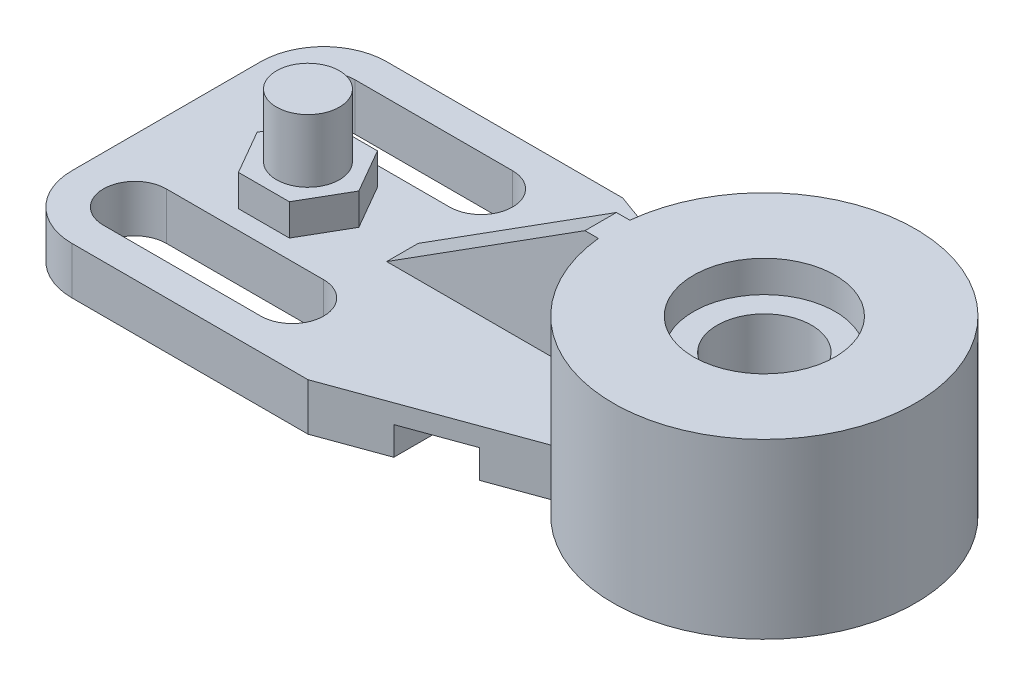
from build123d import *

# Parameters (mm, degrees)
BOSS_EXTRUDE1_DEPTH = 31.75
FILLET1_R           = 12.7
CUT_EXTRUDE1_DEPTH  = 63.5
SKETCH5_R           = 30.48
BOSS_EXTRUDE2_DEPTH = 34.925
SKETCH6_R           = 9.525
CUT_EXTRUDE2_DEPTH  = 35.925
SKETCH7_R           = 14.2875
CUT_EXTRUDE3_DEPTH  = 6.35
CUT_EXTRUDE4_DEPTH  = 10.525
BOSS_EXTRUDE6_DEPTH = 3.175
BOSS_EXTRUDE7_DEPTH = 6.35
SKETCH11_R          = 6.35
BOSS_EXTRUDE8_DEPTH = 12.7


with BuildPart() as part:
    # Sketch2 → Boss-Extrude1 (new body, symmetric)
    with BuildSketch(Plane.XY):
        Polygon((0, 0), (0, 9.525), (-120.65, 9.525), (-120.65, 0), (-47.625, 0), (-47.625, 5.715), (-34.925, 5.715), (-34.925, 0), align=None)
    extrude(amount=BOSS_EXTRUDE1_DEPTH, both=True)

    # Fillet1
    fillet1_edges = [part.edges().sort_by_distance(p)[0] for p in [
        (-120.65, 4.7625, -31.75),
        (-120.65, 4.7625, 31.75),
    ]]
    fillet(fillet1_edges, radius=FILLET1_R)

    # Sketch3 → Cut-Extrude1 (cut)
    with BuildSketch(Plane(origin=(0, 9.525, 0), x_dir=(1, 0, 0), z_dir=(0, 1, 0))):
        with BuildLine():
            Line((-107.95, 25.4), (-76.2, 25.4))
            ThreePointArc((-76.2, 25.4), (-69.85, 19.05), (-76.2, 12.7))
            Line((-76.2, 12.7), (-107.95, 12.7))
            ThreePointArc((-107.95, 12.7), (-114.3, 19.05), (-107.95, 25.4))
        make_face()
        with BuildLine():
            Line((-107.95, -25.4), (-76.2, -25.4))
            ThreePointArc((-76.2, -25.4), (-69.85, -19.05), (-76.2, -12.7))
            Line((-76.2, -12.7), (-107.95, -12.7))
            ThreePointArc((-107.95, -12.7), (-114.3, -19.05), (-107.95, -25.4))
        make_face()
    extrude(amount=-CUT_EXTRUDE1_DEPTH, mode=Mode.SUBTRACT)

    # Sketch5 → Boss-Extrude2 (add)
    with BuildSketch(Plane(origin=(0, 0, 0), x_dir=(1, 0, 0), z_dir=(0, 1, 0))):
        Circle(SKETCH5_R)
    extrude(amount=BOSS_EXTRUDE2_DEPTH)

    # Sketch6 → Cut-Extrude2 (cut, through all)
    with BuildSketch(Plane(origin=(0, 34.925, 0), x_dir=(1, 0, 0), z_dir=(0, 1, 0))):
        Circle(SKETCH6_R)
    extrude(amount=-CUT_EXTRUDE2_DEPTH, mode=Mode.SUBTRACT)

    # Sketch7 → Cut-Extrude3 (cut)
    with BuildSketch(Plane(origin=(0, 34.925, 0), x_dir=(1, 0, 0), z_dir=(0, 1, 0))):
        Circle(SKETCH7_R)
    extrude(amount=-CUT_EXTRUDE3_DEPTH, mode=Mode.SUBTRACT)

    # Sketch8 → Cut-Extrude4 (cut, through all)
    with BuildSketch(Plane(origin=(0, 9.525, 0), x_dir=(1, 0, 0), z_dir=(0, 1, 0))):
        with BuildLine():
            Line((-60.325, 31.75), (-24.157536171, 18.586119717))
            ThreePointArc((-24.157536171, 18.586119717), (-13.463384994, 27.345340819), (0, 30.48))
            Line((0, 30.48), (0, 31.75))
            Line((0, 31.75), (-60.325, 31.75))
        make_face()
        with BuildLine():
            Line((0, -31.75), (-60.325, -31.75))
            Line((-60.325, -31.75), (-24.157536171, -18.586119717))
            ThreePointArc((-24.157536171, -18.586119717), (-13.463384994, -27.345340819), (0, -30.48))
            Line((0, -30.48), (0, -31.75))
        make_face()
    extrude(amount=-CUT_EXTRUDE4_DEPTH, mode=Mode.SUBTRACT)

    # Sketch9 → Boss-Extrude6 (add, symmetric)
    with BuildSketch(Plane.XY):
        Polygon((-73.025, 9.525), (-33.02, 34.925), (-28.575, 34.925), (-28.575, 9.525), align=None)
    extrude(amount=BOSS_EXTRUDE6_DEPTH, both=True)

    # Sketch10 → Boss-Extrude7 (add)
    with BuildSketch(Plane(origin=(0, 9.525, 0), x_dir=(1, 0, 0), z_dir=(0, 1, 0))):
        Polygon((-81.809712214, 0), (-86.942356107, 8.89), (-97.207643893, 8.89), (-102.340287786, 0), (-97.207643893, -8.89), (-86.942356107, -8.89), align=None)
    extrude(amount=BOSS_EXTRUDE7_DEPTH)

    # Sketch11 → Boss-Extrude8 (add)
    with BuildSketch(Plane(origin=(0, 15.875, 0), x_dir=(1, 0, 0), z_dir=(0, 1, 0))):
        with Locations((-92.075, 0)):
            Circle(SKETCH11_R)
    extrude(amount=BOSS_EXTRUDE8_DEPTH)


solid = part.part
